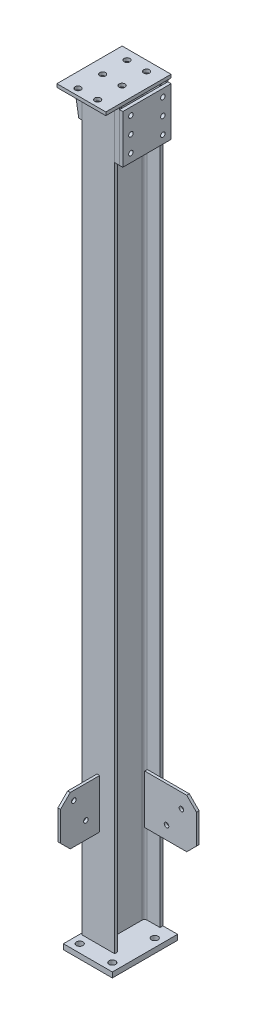
from build123d import *

# Parameters (mm, degrees)
H_HM150_100_7_DEPTH      = 2263
SKETCH_18_W              = 150
SKETCH_18_H              = 200
EXTRUDE_1_DEPTH          = 10
SKETCH_19_R              = 9
CUT_EXTRUDE_4_DEPTH      = 10
SKETCH_20_W              = 150
SKETCH_20_H              = 200
EXTRUDE_2_DEPTH          = 16
SKETCH_22_W              = 8
SKETCH_22_H              = 150
EXTRUDE_4_DEPTH          = 120
CHAMFER_1_SIZE           = 30
SKETCH_23_R              = 7
CUT_EXTRUDE_5_DEPTH      = 8
SKETCH_24_W              = 159
SKETCH_24_H              = 150
EXTRUDE_5_DEPTH          = 8
CHAMFER_2_SIZE           = 30
SKETCH_25_R              = 7
CUT_EXTRUDE_6_DEPTH      = 8
EXTRUDE_6_DEPTH          = 6
SKETCH_26_W              = 15
SKETCH_26_H              = 163
EXTRUDE_6_2_DEPTH        = 6
SKETCH_27_W              = 15
SKETCH_27_H              = 163
EXTRUDE_7_DEPTH          = 6
EXTRUDE_7_2_DEPTH        = 6
SKETCH_28_W              = 10
SKETCH_28_H              = 148
EXTRUDE_8_DEPTH          = 148
SKETCH_29_R              = 7
CUT_EXTRUDE_7_DEPTH      = 2287.19006209
CUT_EXTRUDE_7_DEPTH_BACK = 10
SKETCH_30_R              = 10
CUT_EXTRUDE_8_DEPTH      = 16


with BuildPart() as part:
    # 草图1 → H型钢 HM150×100(7) (new body)
    with BuildSketch(Plane(origin=(0, 0, 0), x_dir=(1, 0, 0), z_dir=(0, 1, 0))):
        with BuildLine():
            Line((-50, -74), (50, -74))
            Line((50, -74), (50, -65))
            Line((50, -65), (11, -65))
            ThreePointArc((11, -65), (5.343145751, -62.656854249), (3, -57))
            Line((3, -57), (3, 57))
            ThreePointArc((3, 57), (5.343145751, 62.656854249), (11, 65))
            Line((11, 65), (50, 65))
            Line((50, 65), (50, 74))
            Line((50, 74), (-50, 74))
            Line((-50, 74), (-50, 65))
            Line((-50, 65), (-11, 65))
            ThreePointArc((-11, 65), (-5.343145751, 62.656854249), (-3, 57))
            Line((-3, 57), (-3, -57))
            ThreePointArc((-3, -57), (-5.343145751, -62.656854249), (-11, -65))
            Line((-11, -65), (-50, -65))
            Line((-50, -65), (-50, -74))
        make_face()
    extrude(amount=H_HM150_100_7_DEPTH)


with BuildPart() as body_2:
    # 草图18 → 凸台-拉伸1 (new body)
    with BuildSketch(Plane(origin=(0, 2263, 0), x_dir=(1, 0, 0), z_dir=(0, 1, 0))):
        with Locations((0, -26)):
            Rectangle(SKETCH_18_W, SKETCH_18_H)
    extrude(amount=EXTRUDE_1_DEPTH)

    # 草图19 → 切除-拉伸4 (cut)
    with BuildSketch(Plane(origin=(0, 2273, 0), x_dir=(1, 0, 0), z_dir=(0, 1, 0))):
        with Locations(Location((-30, 44, 0), (0, 0, 270))):
            Circle(SKETCH_19_R)
        with Locations(Location((30, 44, 0), (0, 0, 270))):
            Circle(SKETCH_19_R)
        with Locations(Location((-30, -31, 0), (0, 0, 270))):
            Circle(SKETCH_19_R)
        with Locations(Location((30, -31, 0), (0, 0, 270))):
            Circle(SKETCH_19_R)
        with Locations(Location((-30, -106, 0), (0, 0, 270))):
            Circle(SKETCH_19_R)
        with Locations(Location((30, -106, 0), (0, 0, 270))):
            Circle(SKETCH_19_R)
    extrude(amount=-CUT_EXTRUDE_4_DEPTH, mode=Mode.SUBTRACT)


with BuildPart() as body_3:
    # 草图20 → 凸台-拉伸2 (new body)
    with BuildSketch(Plane.XZ):
        with Locations((20, 26)):
            Rectangle(SKETCH_20_W, SKETCH_20_H)
    extrude(amount=EXTRUDE_2_DEPTH)

    # 草图30 → 切除-拉伸8 (cut)
    with BuildSketch(Plane.XZ.offset(16)):
        with Locations(Location((70, 101, 0), (0, 0, 270))):
            Circle(SKETCH_30_R)
        with Locations(Location((-30, 101, 0), (0, 0, 270))):
            Circle(SKETCH_30_R)
        with Locations(Location((-30, -29, 0), (0, 0, 270))):
            Circle(SKETCH_30_R)
        with Locations(Location((70, -29, 0), (0, 0, 270))):
            Circle(SKETCH_30_R)
    extrude(amount=-CUT_EXTRUDE_8_DEPTH, mode=Mode.SUBTRACT)


with BuildPart() as body_4:
    # 草图22 → 凸台-拉伸4 (new body)
    with BuildSketch(Plane.XY.offset(74)):
        with Locations((0, 375)):
            Rectangle(SKETCH_22_W, SKETCH_22_H)
    extrude(amount=EXTRUDE_4_DEPTH)

    # 倒角1
    chamfer_1_edges = [body_4.edges().sort_by_distance(p)[0] for p in [
        (0, 300, 194),
        (0, 450, 194),
    ]]
    chamfer(chamfer_1_edges, length=CHAMFER_1_SIZE)

    # 草图23 → 切除-拉伸5 (cut)
    with BuildSketch(Plane.ZY.offset(4)):
        with Locations((116.069486629, 352)):
            Circle(SKETCH_23_R)
        with Locations((153.009375687, 422.960866654)):
            Circle(SKETCH_23_R)
    extrude(amount=-CUT_EXTRUDE_5_DEPTH, mode=Mode.SUBTRACT)


with BuildPart() as body_5:
    # 草图24 → 凸台-拉伸5 (new body)
    with BuildSketch(Plane.XY.offset(-65)):
        with Locations((90.5, 325)):
            Rectangle(SKETCH_24_W, SKETCH_24_H)
    extrude(amount=EXTRUDE_5_DEPTH)

    # 倒角2
    chamfer_2_edges = [body_5.edges().sort_by_distance(p)[0] for p in [
        (170, 250, -61),
        (170, 400, -61),
    ]]
    chamfer(chamfer_2_edges, length=CHAMFER_2_SIZE)

    # 草图25 → 切除-拉伸6 (cut)
    with BuildSketch(Plane(origin=(0, 0, -65), x_dir=(-1, 0, 0), z_dir=(0, 0, -1))):
        with Locations((-78.008301528, 290)):
            Circle(SKETCH_25_R)
        with Locations((-123.894416436, 355.532163543)):
            Circle(SKETCH_25_R)
    extrude(amount=-CUT_EXTRUDE_6_DEPTH, mode=Mode.SUBTRACT)


with BuildPart() as body_6:
    # 草图26 → 凸台-拉伸6 (new body)
    with BuildSketch(Plane.XY.offset(74)):
        Polygon((-50, 2263), (-75, 2263), (-75, 2253), (-60, 2163), (-50, 2163), align=None)
    extrude(amount=-EXTRUDE_6_DEPTH)


with BuildPart() as body_7:
    # 草图26 → Extrude 6 2 (new body)
    with BuildSketch(Plane.XY.offset(74)):
        with Locations((57.5, 2181.5)):
            Rectangle(SKETCH_26_W, SKETCH_26_H)
    extrude(amount=-EXTRUDE_6_2_DEPTH)


with BuildPart() as body_8:
    # 草图27 → 凸台-拉伸7 (new body)
    with BuildSketch(Plane(origin=(0, 0, -74), x_dir=(-1, 0, 0), z_dir=(0, 0, -1))):
        with Locations((-57.5, 2181.5)):
            Rectangle(SKETCH_27_W, SKETCH_27_H)
    extrude(amount=-EXTRUDE_7_DEPTH)


with BuildPart() as body_9:
    # 草图27 → Extrude 7 2 (new body)
    with BuildSketch(Plane(origin=(0, 0, -74), x_dir=(-1, 0, 0), z_dir=(0, 0, -1))):
        Polygon((50, 2263), (50, 2163), (60, 2163), (75, 2253), (75, 2263), align=None)
    extrude(amount=-EXTRUDE_7_2_DEPTH)


with BuildPart() as body_10:
    # 草图28 → 凸台-拉伸8 (new body)
    with BuildSketch(Plane.XY.offset(74)):
        with Locations((70, 2174)):
            Rectangle(SKETCH_28_W, SKETCH_28_H)
    extrude(amount=-EXTRUDE_8_DEPTH)

    # 草图29 → 切除-拉伸7 (cut, two sides)
    with BuildSketch(Plane(origin=(75, 0, 0), x_dir=(0, 0, -1), z_dir=(1, 0, 0))) as cut_extrude_7_sk:
        with Locations(Location((-49, 2225, 0), (0, 0, 180))):
            Circle(SKETCH_29_R)
        with Locations(Location((49, 2225, 0), (0, 0, 180))):
            Circle(SKETCH_29_R)
        with Locations(Location((49, 2175, 0), (0, 0, 180))):
            Circle(SKETCH_29_R)
        with Locations(Location((-49, 2175, 0), (0, 0, 180))):
            Circle(SKETCH_29_R)
        with Locations(Location((49, 2125, 0), (0, 0, 180))):
            Circle(SKETCH_29_R)
        with Locations(Location((-49, 2125, 0), (0, 0, 180))):
            Circle(SKETCH_29_R)
    extrude(amount=CUT_EXTRUDE_7_DEPTH, mode=Mode.SUBTRACT)
    extrude(cut_extrude_7_sk.sketch, amount=-CUT_EXTRUDE_7_DEPTH_BACK, mode=Mode.SUBTRACT)


solid = Compound([part.part, body_2.part, body_3.part, body_4.part, body_5.part, body_6.part, body_7.part, body_8.part, body_9.part, body_10.part])
